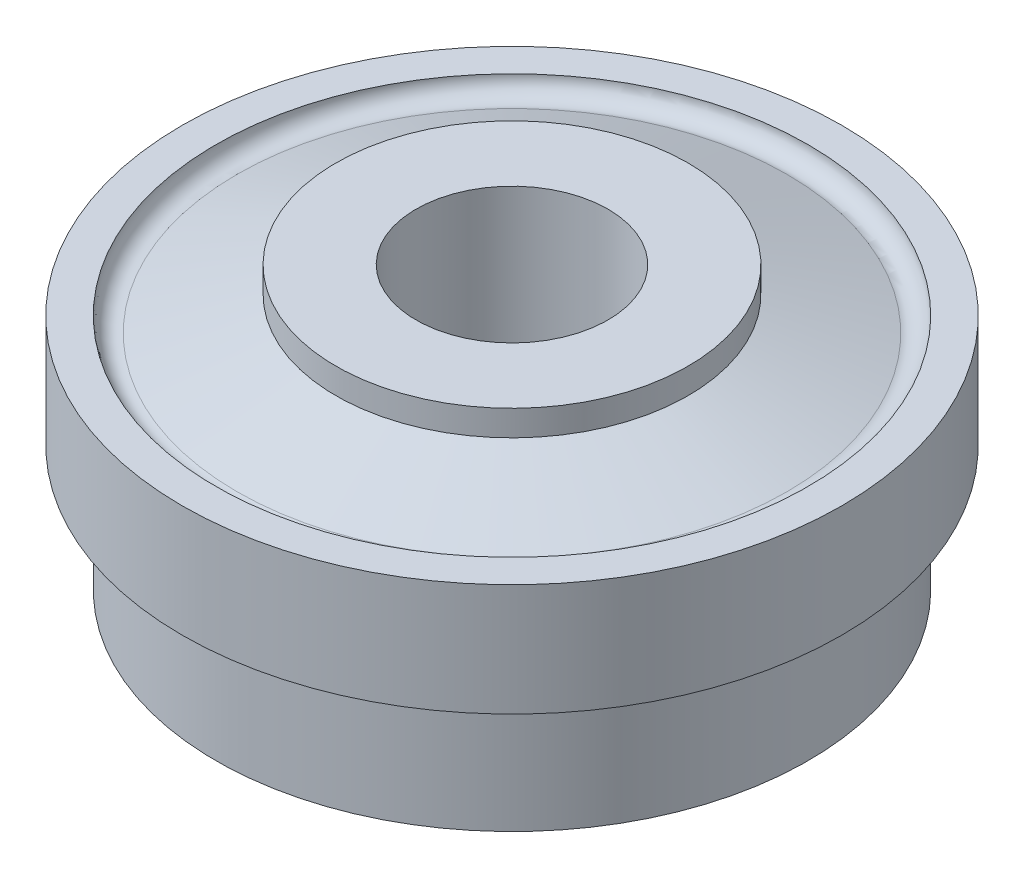
from build123d import *


with BuildPart() as part:
    # Sketch1 → Revolve1 (revolve)
    with BuildSketch(Plane.XY):
        with BuildLine():
            Line((30, 76), (30, 0))
            Line((30, 0), (55, 0))
            Line((55, 0), (55, 45))
            ThreePointArc((55, 45), (58.132644659, 50.270509781), (64.259424449, 50.03747479))
            Line((64.259424449, 50.03747479), (87.5, 35))
            Line((87.5, 35), (87.5, -12))
            Line((87.5, -12), (92.5, -12))
            Line((92.5, -12), (92.5, 27.206415499))
            Line((92.5, 27.206415499), (103, 27.206415499))
            Line((103, 27.206415499), (103, 62.206415499))
            Line((103, 62.206415499), (92.5, 62.206415499))
            ThreePointArc((92.5, 62.206415499), (90.409938476, 58.140427542), (85.887096774, 57.473705579))
            Line((85.887096774, 57.473705579), (55, 68))
            Line((55, 68), (55, 76))
            Line((55, 76), (30, 76))
        make_face()
    revolve(axis=Axis((0, -19.792449206, 0), (0, 1, 0)))


solid = part.part
